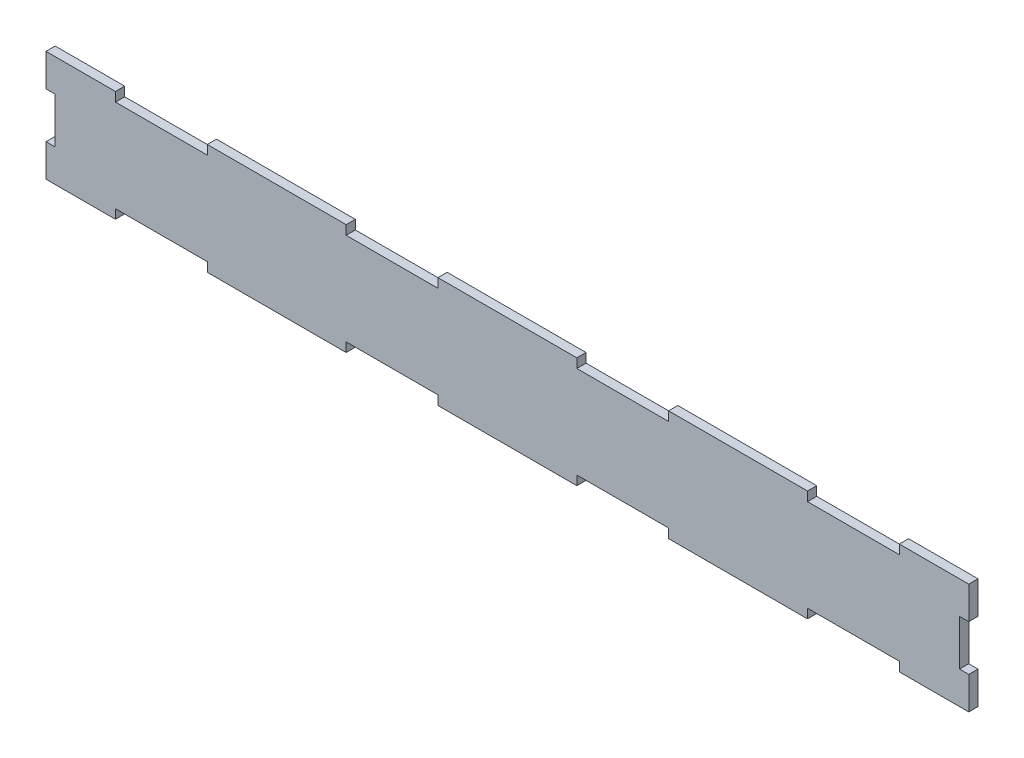
from build123d import *

# Parameters (mm, degrees)
BOSS_EXTRUDE1_DEPTH = 8


with BuildPart() as part:
    # Sketch1 → Boss-Extrude1 (new body)
    with BuildSketch(Plane.XY):
        Polygon((-392, -19.8), (-392, 19.8), (-400, 19.8), (-400, 48), (-339.8, 48), (-339.8, 40), (-260.2, 40), (-260.2, 48), (-139.8, 48), (-139.8, 40), (-60.2, 40), (-60.2, 48), (60.2, 48), (60.2, 40), (139.8, 40), (139.8, 48), (260.2, 48), (260.2, 40), (339.8, 40), (339.8, 48), (400, 48), (400, 19.8), (392, 19.8), (392, -19.8), (400, -19.8), (400, -48), (339.8, -48), (339.8, -40), (260.2, -40), (260.2, -48), (139.8, -48), (139.8, -40), (60.2, -40), (60.2, -48), (-60.2, -48), (-60.2, -40), (-139.8, -40), (-139.8, -48), (-260.2, -48), (-260.2, -40), (-339.8, -40), (-339.8, -48), (-400, -48), (-400, -19.8), align=None)
    extrude(amount=BOSS_EXTRUDE1_DEPTH)


solid = part.part
